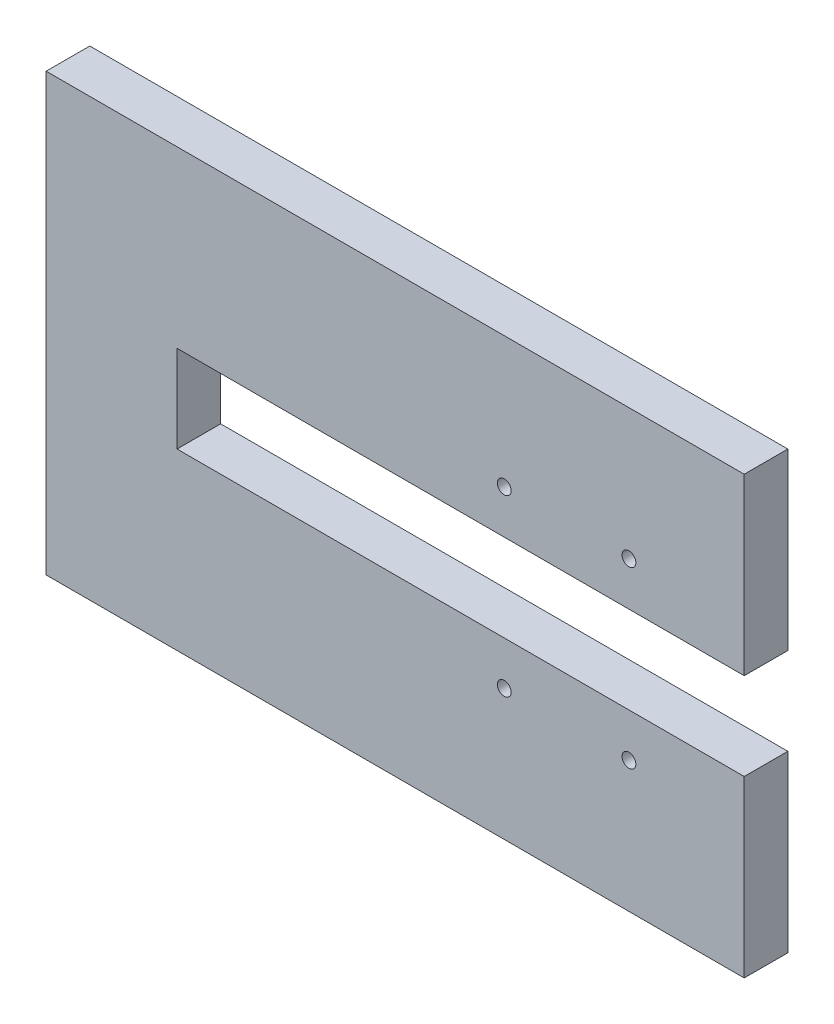
from build123d import *

# Parameters (mm, degrees)
SKETCH1_R           = 1.5875
BOSS_EXTRUDE1_DEPTH = 10


with BuildPart() as part:
    # Sketch1 → Boss-Extrude1 (new body)
    with BuildSketch(Plane.XY):
        Polygon((-53.537623716, 64.885018665), (106.462376284, 64.885018665), (106.462376284, 24.885018665), (-23.537623716, 24.885018665), (-23.537623716, 4.885018665), (106.462376284, 4.885018665), (106.462376284, -35.114981335), (-53.537623716, -35.114981335), align=None)
        with Locations((51.462376284, 34.885018665)):
            Circle(SKETCH1_R, mode=Mode.SUBTRACT)
        with Locations((80.037376284, 34.885018665)):
            Circle(SKETCH1_R, mode=Mode.SUBTRACT)
        with Locations((51.462376284, -5.114981335)):
            Circle(SKETCH1_R, mode=Mode.SUBTRACT)
        with Locations((80.037376284, -5.114981335)):
            Circle(SKETCH1_R, mode=Mode.SUBTRACT)
    extrude(amount=BOSS_EXTRUDE1_DEPTH)


solid = part.part
